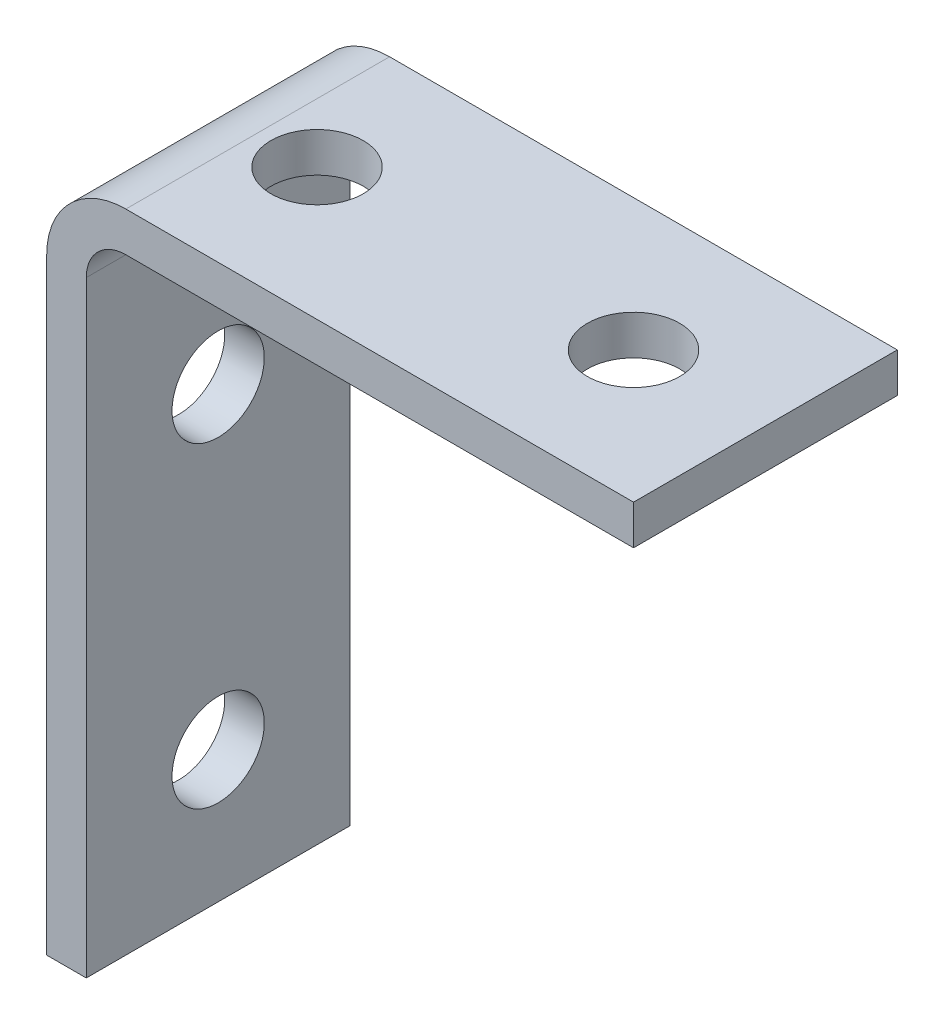
from build123d import *

# Parameters (mm, degrees)
SKETCH1_W                      = 89
SKETCH1_H                      = 104
BOSS_EXTRUDE1_DEPTH            = 40
SKETCH2_W                      = 83
SKETCH2_H                      = 98
CUT_EXTRUDE1_DEPTH             = 41
F_14_0_14_DIAMETER_HOLE1_D     = 14
F_14_0_14_DIAMETER_HOLE1_DEPTH = 89
F_14_0_14_DIAMETER_HOLE2_D     = 14
F_14_0_14_DIAMETER_HOLE2_DEPTH = 6
FILLET1_R                      = 6
FILLET2_R                      = 12


with BuildPart() as part:
    # Sketch1 → Boss-Extrude1 (new body)
    with BuildSketch(Plane.XY):
        with Locations((44.5, 52)):
            Rectangle(SKETCH1_W, SKETCH1_H)
    extrude(amount=-BOSS_EXTRUDE1_DEPTH)

    # Sketch2 → Cut-Extrude1 (cut, through all)
    with BuildSketch(Plane(origin=(0, 0, -40), x_dir=(-1, 0, 0), z_dir=(0, 0, -1))):
        with Locations((-47.5, 49)):
            Rectangle(SKETCH2_W, SKETCH2_H)
    extrude(amount=-CUT_EXTRUDE1_DEPTH, mode=Mode.SUBTRACT)

    # Ø14.0 (14) Diameter Hole1
    with Locations(Plane.ZY):
        with Locations((-20, 68), (-20, 20)):
            Hole(F_14_0_14_DIAMETER_HOLE1_D / 2, depth=F_14_0_14_DIAMETER_HOLE1_DEPTH)

    # Ø14.0 (14) Diameter Hole2
    with Locations(Plane(origin=(0, 98, 0), x_dir=(-1, 0, 0), z_dir=(0, -1, 0))):
        with Locations((-69, 20), (-21, 20)):
            Hole(F_14_0_14_DIAMETER_HOLE2_D / 2, depth=F_14_0_14_DIAMETER_HOLE2_DEPTH)

    # Fillet1
    fillet1_edges = [part.edges().sort_by_distance(p)[0] for p in [
        (6, 98, -20),
    ]]
    fillet(fillet1_edges, radius=FILLET1_R)

    # Fillet2
    fillet2_edges = [part.edges().sort_by_distance(p)[0] for p in [
        (0, 104, -20),
    ]]
    fillet(fillet2_edges, radius=FILLET2_R)


solid = part.part
